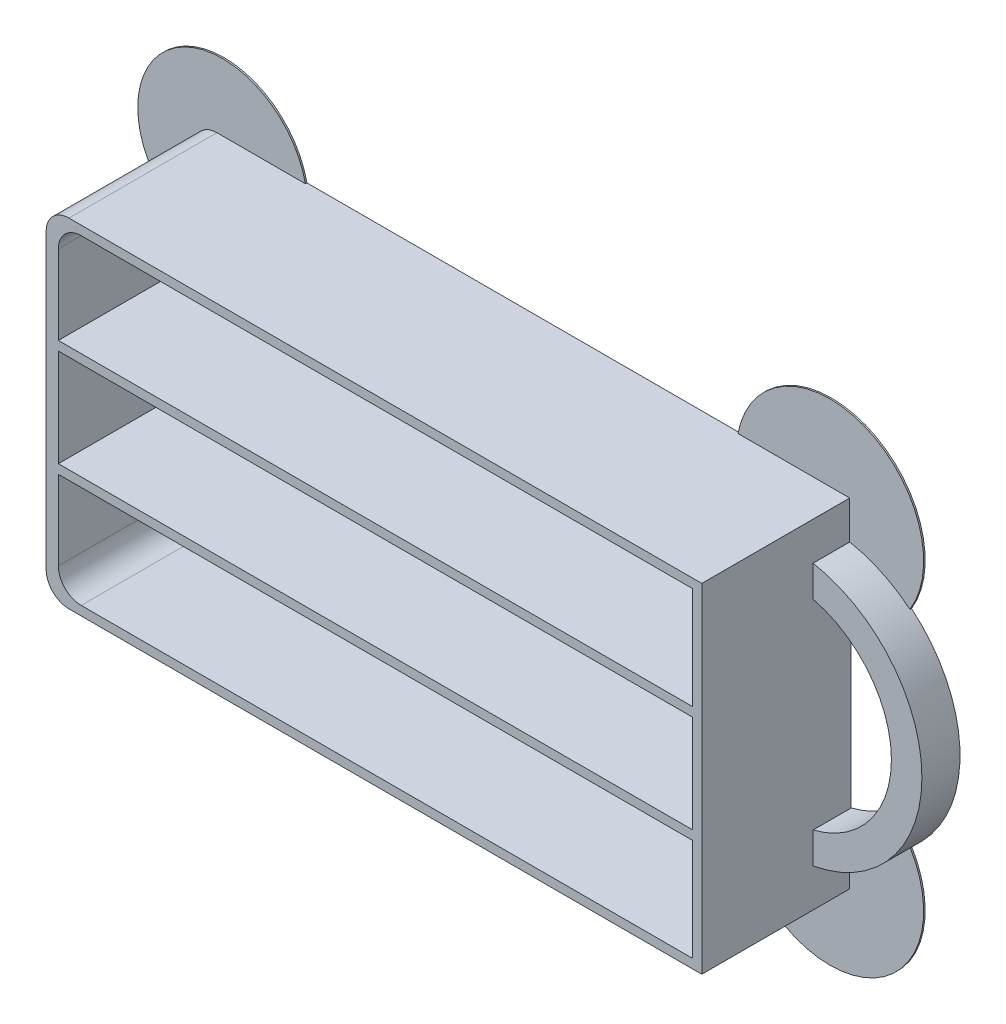
from build123d import *

# Parameters (mm, degrees)
SKETCH_1_W          = 86
SKETCH_1_H          = 44.4
EXTRUDE_1_DEPTH     = 19.6
EXTRUDE_2_DEPTH     = 5
SKETCH_3_W          = 83.2
SKETCH_3_H          = 13.4
SKETCH_3_H_2        = 12.8
CUT_EXTRUDE_1_DEPTH = 18.4
FILLET_1_R          = 3
EXTRUDE_3_DEPTH     = 0.2


with BuildPart() as part:
    # Эскиз1 → Бобышка-Вытянуть1 (new body)
    with BuildSketch(Plane.XY):
        Rectangle(SKETCH_1_W, SKETCH_1_H)
    extrude(amount=EXTRUDE_1_DEPTH)

    # Эскиз2 → Бобышка-Вытянуть2 (add)
    with BuildSketch(Plane.XY):
        with BuildLine():
            Line((43, 17.2), (43, 13.108775687))
            ThreePointArc((43, 13.108775687), (53.273546839, 0), (43, -13.108775687))
            Line((43, -13.108775687), (43, -17.2))
            ThreePointArc((43, -17.2), (57.273546839, 0), (43, 17.2))
        make_face()
    extrude(amount=EXTRUDE_2_DEPTH)

    # Эскиз3 → Вырез-Вытянуть1 (cut)
    with BuildSketch(Plane.XY.offset(19.6)):
        with Locations((0.2, 14.3)):
            Rectangle(SKETCH_3_W, SKETCH_3_H)
        with Locations((0.2, 0)):
            Rectangle(SKETCH_3_W, SKETCH_3_H_2)
        with Locations((0.2, -14.3)):
            Rectangle(SKETCH_3_W, SKETCH_3_H)
    extrude(amount=-CUT_EXTRUDE_1_DEPTH, mode=Mode.SUBTRACT)

    # Скругление1
    fillet_1_edges = [part.edges().sort_by_distance(p)[0] for p in [
        (-41.4, 21, 10.4),
        (-41.4, -21, 10.4),
        (-43, -22.2, 9.8),
        (-43, 22.2, 9.8),
    ]]
    fillet(fillet_1_edges, radius=FILLET_1_R)

    # Эскиз4 → Бобышка-Вытянуть3 (add)
    with BuildSketch(Plane(origin=(0, 0, 0), x_dir=(-1, 0, 0), z_dir=(0, 0, -1))):
        with BuildLine():
            Line((-50.908934574, 13.500116296), (-28.350220542, 22.2))
            ThreePointArc((-28.350220542, 22.2), (-44.835714922, 31.349521818), (-50.908934574, 13.500116296))
        make_face()
        with BuildLine():
            Line((43, 9.417902962), (28.395750511, 22.2))
            ThreePointArc((28.395750511, 22.2), (46.588074999, 28.251604167), (43, 9.417902962))
        make_face()
        with BuildLine():
            Line((43, -9.417902962), (28.395750511, -22.2))
            ThreePointArc((28.395750511, -22.2), (46.588074999, -28.251604167), (43, -9.417902962))
        make_face()
        with BuildLine():
            Line((-50.908934574, -13.500116296), (-28.350220542, -22.2))
            ThreePointArc((-28.350220542, -22.2), (-44.835714922, -31.349521818), (-50.908934574, -13.500116296))
        make_face()
    extrude(amount=-EXTRUDE_3_DEPTH)


solid = part.part
